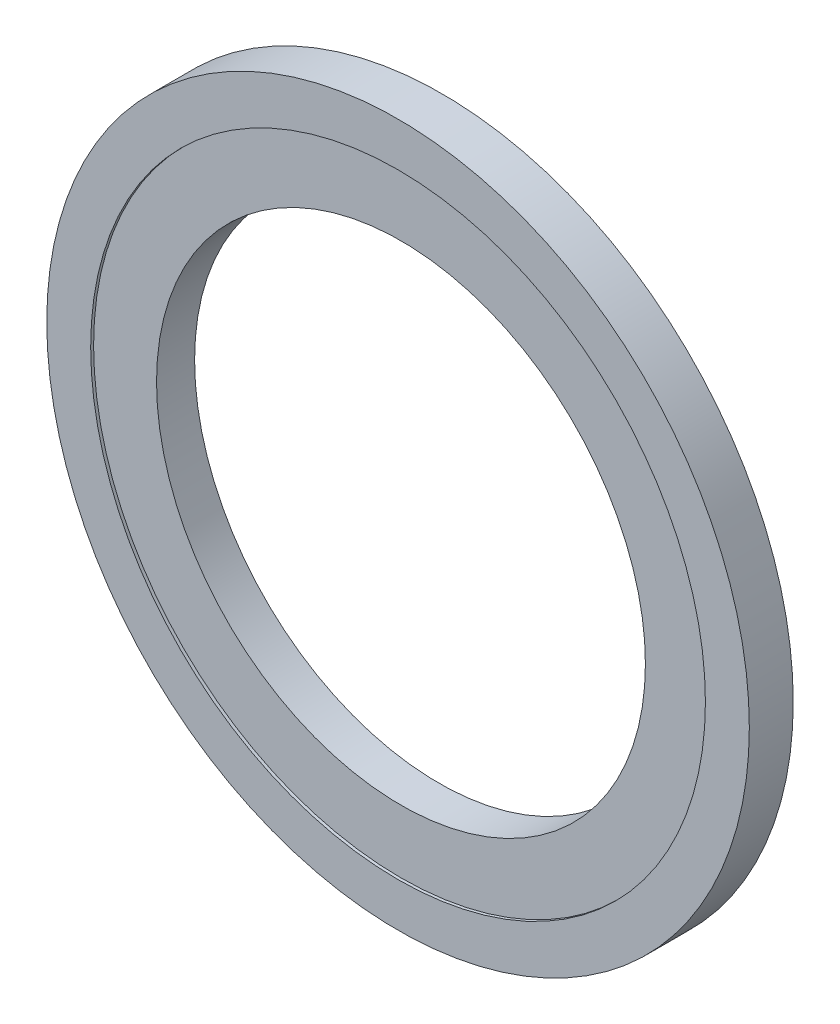
from build123d import *

# Parameters (mm, degrees)
SKETCH1_R           = 12
SKETCH1_R_2         = 8.35
BOSS_EXTRUDE1_DEPTH = 1.5
SKETCH3_R           = 10.5
CUT_EXTRUDE1_DEPTH  = 0.1
CUT_EXTRUDE2_START  = -0.1
SKETCH4_R           = 10.5
CUT_EXTRUDE2_DEPTH  = 0.1


with BuildPart() as part:
    # Sketch1 → Boss-Extrude1 (new body)
    with BuildSketch(Plane.XY):
        Circle(SKETCH1_R)
        Circle(SKETCH1_R_2, mode=Mode.SUBTRACT)
    extrude(amount=BOSS_EXTRUDE1_DEPTH)

    # Sketch3 → Cut-Extrude1 (cut)
    with BuildSketch(Plane.XY.offset(1.5)):
        Circle(SKETCH3_R)
    extrude(amount=-CUT_EXTRUDE1_DEPTH, mode=Mode.SUBTRACT)

    # Sketch4 → Cut-Extrude2 (cut)
    with BuildSketch(Plane(origin=(0, 0, 0), x_dir=(-1, 0, 0), z_dir=(0, 0, -1)).offset(CUT_EXTRUDE2_START)):
        Circle(SKETCH4_R)
    extrude(amount=CUT_EXTRUDE2_DEPTH, mode=Mode.SUBTRACT)


solid = part.part
